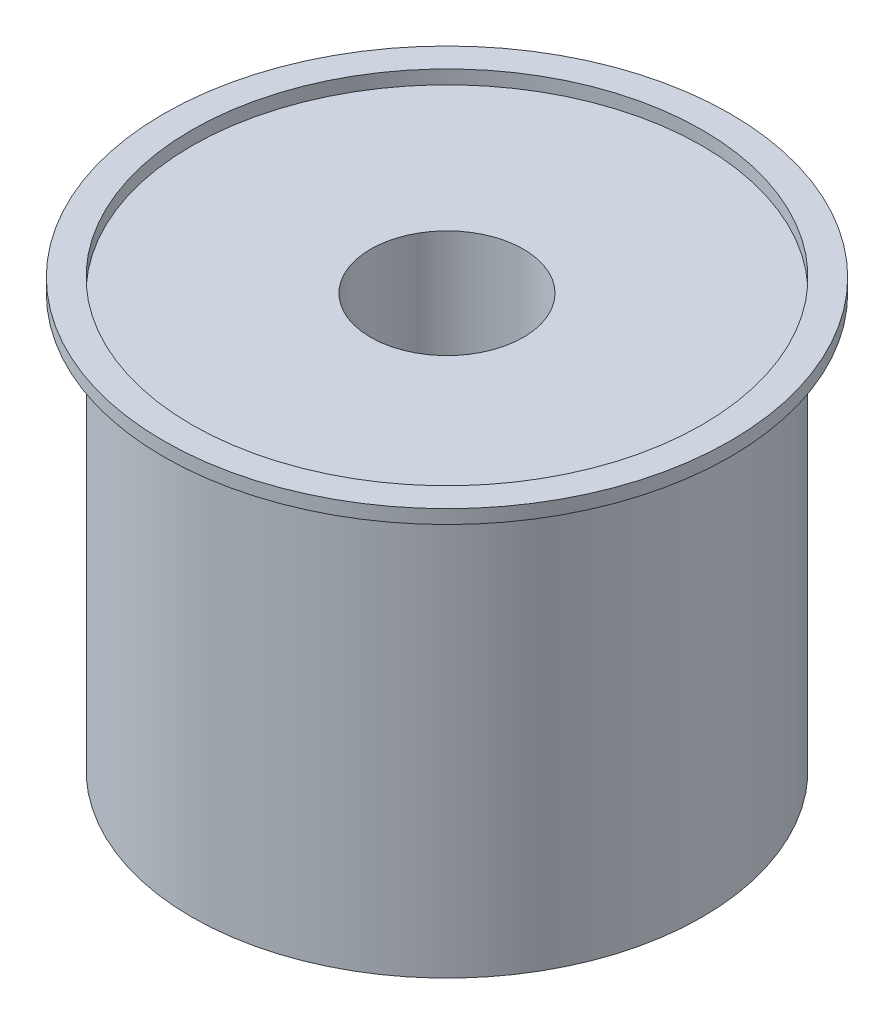
from build123d import *

# Parameters (mm, degrees)
CROQUIS1_R              = 185.569887542
CROQUIS1_R_2            = 55.569887542
SALIENTE_EXTRUIR1_DEPTH = 300
CROQUIS2_R              = 205.981548736
CROQUIS2_R_2            = 185.569887542
SALIENTE_EXTRUIR2_DEPTH = 10


with BuildPart() as part:
    # Croquis1 → Saliente-Extruir1 (new body)
    with BuildSketch(Plane(origin=(0, 0, 0), x_dir=(1, 0, 0), z_dir=(0, 1, 0))):
        Circle(CROQUIS1_R)
        Circle(CROQUIS1_R_2, mode=Mode.SUBTRACT)
    extrude(amount=SALIENTE_EXTRUIR1_DEPTH)


with BuildPart() as body_2:
    # Croquis2 → Saliente-Extruir2 (new body)
    with BuildSketch(Plane(origin=(0, 300, 0), x_dir=(1, 0, 0), z_dir=(0, 1, 0))):
        Circle(CROQUIS2_R)
        Circle(CROQUIS2_R_2, mode=Mode.SUBTRACT)
    extrude(amount=SALIENTE_EXTRUIR2_DEPTH)


solid = Compound([part.part, body_2.part])
